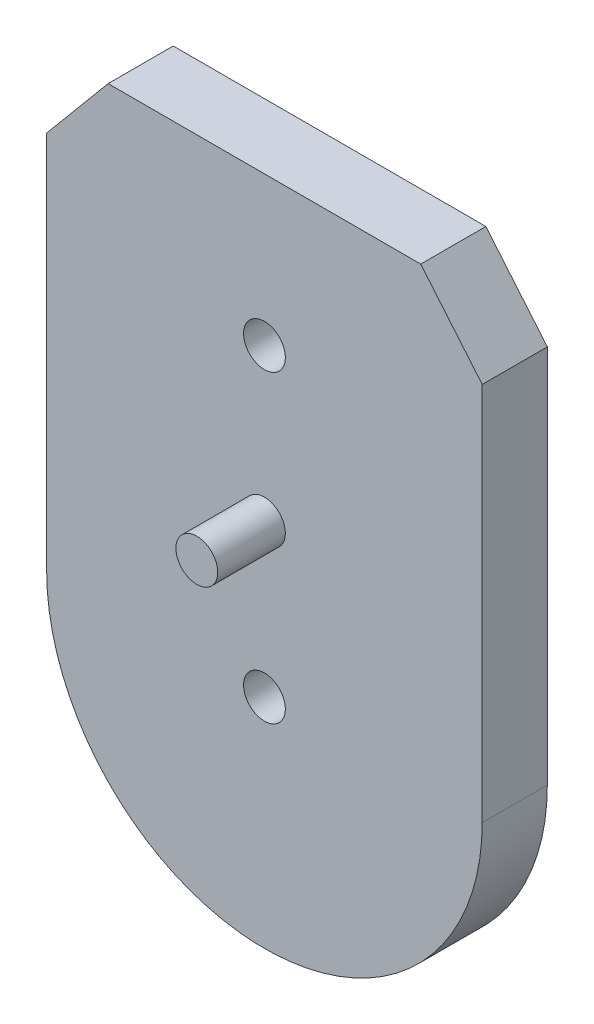
from build123d import *

# Parameters (mm, degrees)
SKETCH1_R           = 12
BOSS_EXTRUDE1_DEPTH = 18.6875
SKETCH1_4_R         = 12
BOSS_EXTRUDE2_DEPTH = 57.5


with BuildPart() as part:
    # Sketch1 → Boss-Extrude1 (new, symmetric)
    with BuildSketch(Plane.XY):
        with BuildLine():
            Line((125, -137.375), (125, 80.499531502))
            Line((125, 80.499531502), (89.723613553, 122.703318674))
            Line((89.723613553, 122.703318674), (-89.72361368, 122.703318674))
            Line((-89.72361368, 122.703318674), (-125, 80.499531502))
            Line((-125, 80.499531502), (-125, -137.375))
            ThreePointArc((-125, -137.375), (0, -262.375), (125, -137.375))
        make_face()
        with Locations((0, -137.375)):
            Circle(SKETCH1_R, mode=Mode.SUBTRACT)
        with Locations((0, 37.375)):
            Circle(SKETCH1_R, mode=Mode.SUBTRACT)
    extrude(amount=BOSS_EXTRUDE1_DEPTH, both=True)

    # Sketch1_4 → Boss-Extrude2 (add)
    with BuildSketch(Plane.XY):
        with Locations((0, -50)):
            Circle(SKETCH1_4_R)
    extrude(amount=BOSS_EXTRUDE2_DEPTH)


solid = part.part
